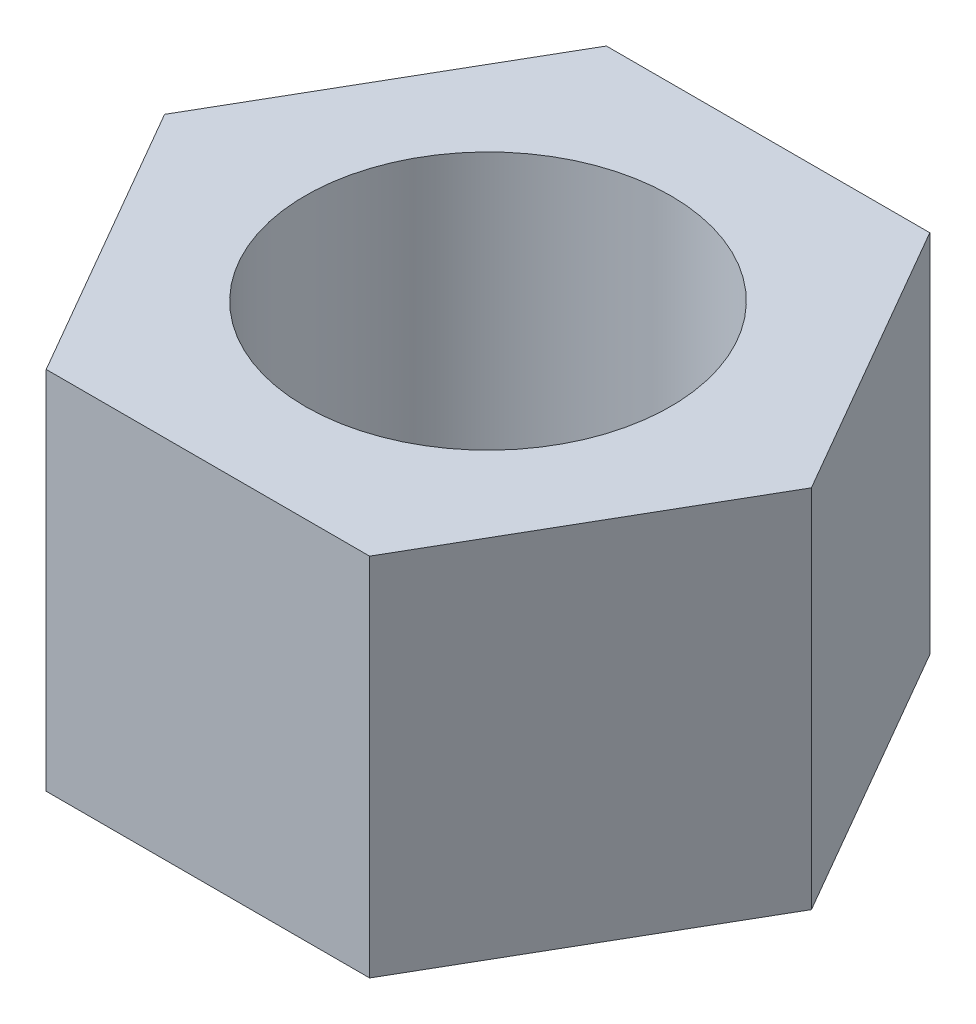
from build123d import *

# Parameters (mm, degrees)
SKETCH_1_R      = 1.5
EXTRUDE_2_DEPTH = 3


with BuildPart() as part:
    # 草图1 → 凸台-拉伸2 (new body)
    with BuildSketch(Plane(origin=(0, 0, 0), x_dir=(1, 0, 0), z_dir=(0, 1, 0))):
        Polygon((-1.327905619, 2.3), (-2.655811238, 0), (-1.327905619, -2.3), (1.327905619, -2.3), (2.655811238, 0), (1.327905619, 2.3), align=None)
        Circle(SKETCH_1_R, mode=Mode.SUBTRACT)
    extrude(amount=EXTRUDE_2_DEPTH)


solid = part.part
